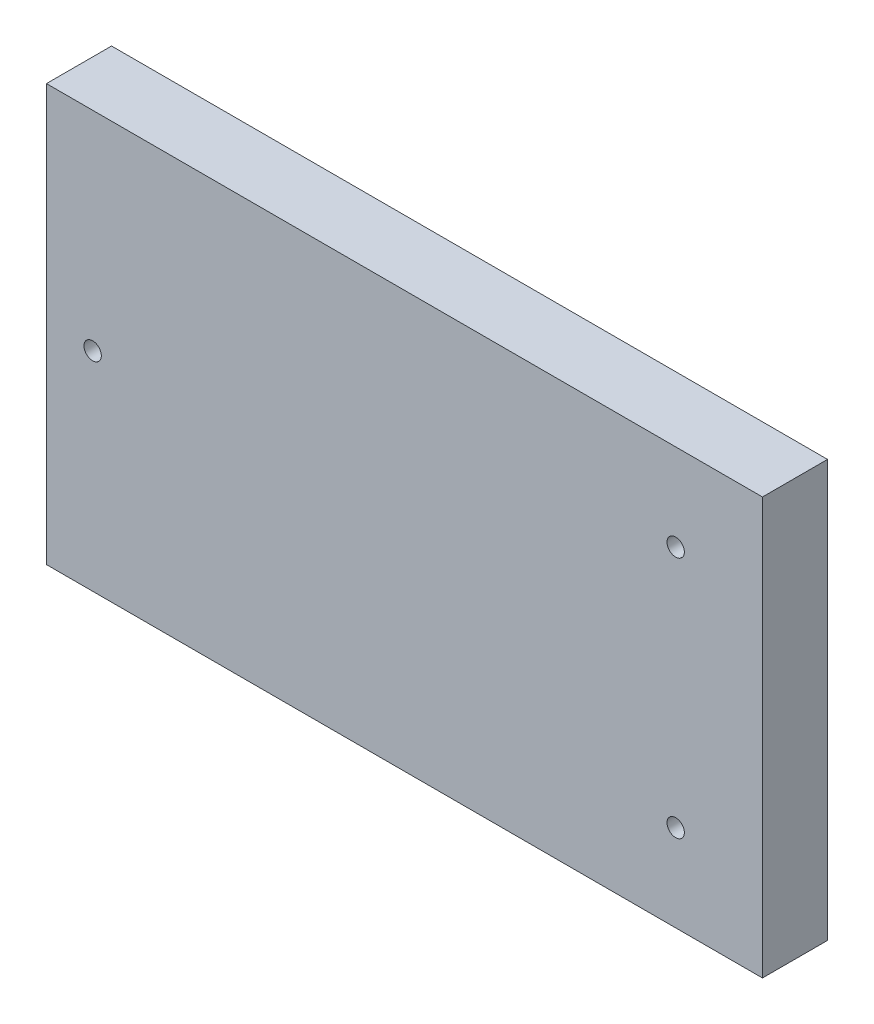
from build123d import *

# Parameters (mm, degrees)
SKETCH1_W           = 165
SKETCH1_H           = 96
SKETCH1_R           = 2
BOSS_EXTRUDE1_DEPTH = 15


with BuildPart() as part:
    # Sketch1 → Boss-Extrude1 (new body)
    with BuildSketch(Plane.XY):
        with Locations((623.034520475, 268.509389187)):
            Rectangle(SKETCH1_W, SKETCH1_H)
        with Locations((685.534520475, 296.509389187)):
            Circle(SKETCH1_R, mode=Mode.SUBTRACT)
        with Locations((685.534520475, 240.509389187)):
            Circle(SKETCH1_R, mode=Mode.SUBTRACT)
        with Locations((551.183631115, 268.509389187)):
            Circle(SKETCH1_R, mode=Mode.SUBTRACT)
    extrude(amount=BOSS_EXTRUDE1_DEPTH)


solid = part.part
